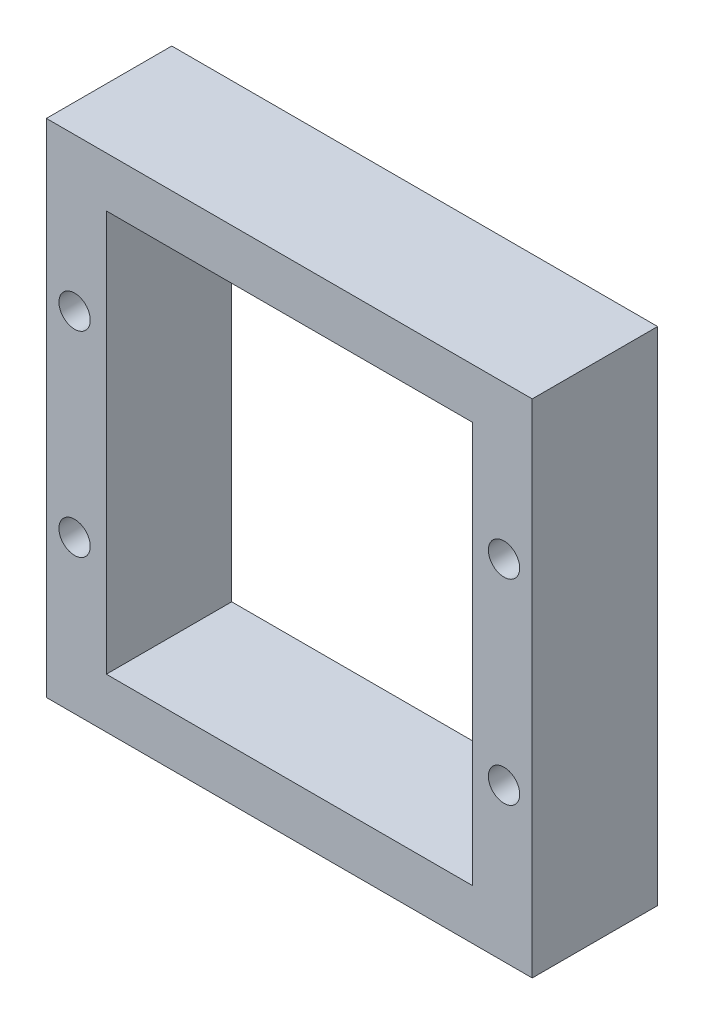
from build123d import *

# Parameters (mm, degrees)
SKETCH1_W           = 31
SKETCH1_H           = 32
BOSS_EXTRUDE1_DEPTH = 8
SKETCH2_W           = 23.35
SKETCH2_H           = 25.6
CUT_EXTRUDE1_DEPTH  = 13
SKETCH3_R           = 1
CUT_EXTRUDE2_DEPTH  = 10


with BuildPart() as part:
    # Sketch1 → Boss-Extrude1 (new body)
    with BuildSketch(Plane.XY):
        Rectangle(SKETCH1_W, SKETCH1_H)
    extrude(amount=BOSS_EXTRUDE1_DEPTH)

    # Sketch2 → Cut-Extrude1 (cut)
    with BuildSketch(Plane.XY.offset(8)):
        Rectangle(SKETCH2_W, SKETCH2_H)
    extrude(amount=-CUT_EXTRUDE1_DEPTH, mode=Mode.SUBTRACT)

    # Sketch3 → Cut-Extrude2 (cut)
    with BuildSketch(Plane.XY.offset(8)):
        with Locations((13.7, 6.25)):
            Circle(SKETCH3_R)
        with Locations((13.7, -6.25)):
            Circle(SKETCH3_R)
        with Locations((-13.7, -6.25)):
            Circle(SKETCH3_R)
        with Locations((-13.7, 6.25)):
            Circle(SKETCH3_R)
    extrude(amount=-CUT_EXTRUDE2_DEPTH, mode=Mode.SUBTRACT)


solid = part.part
